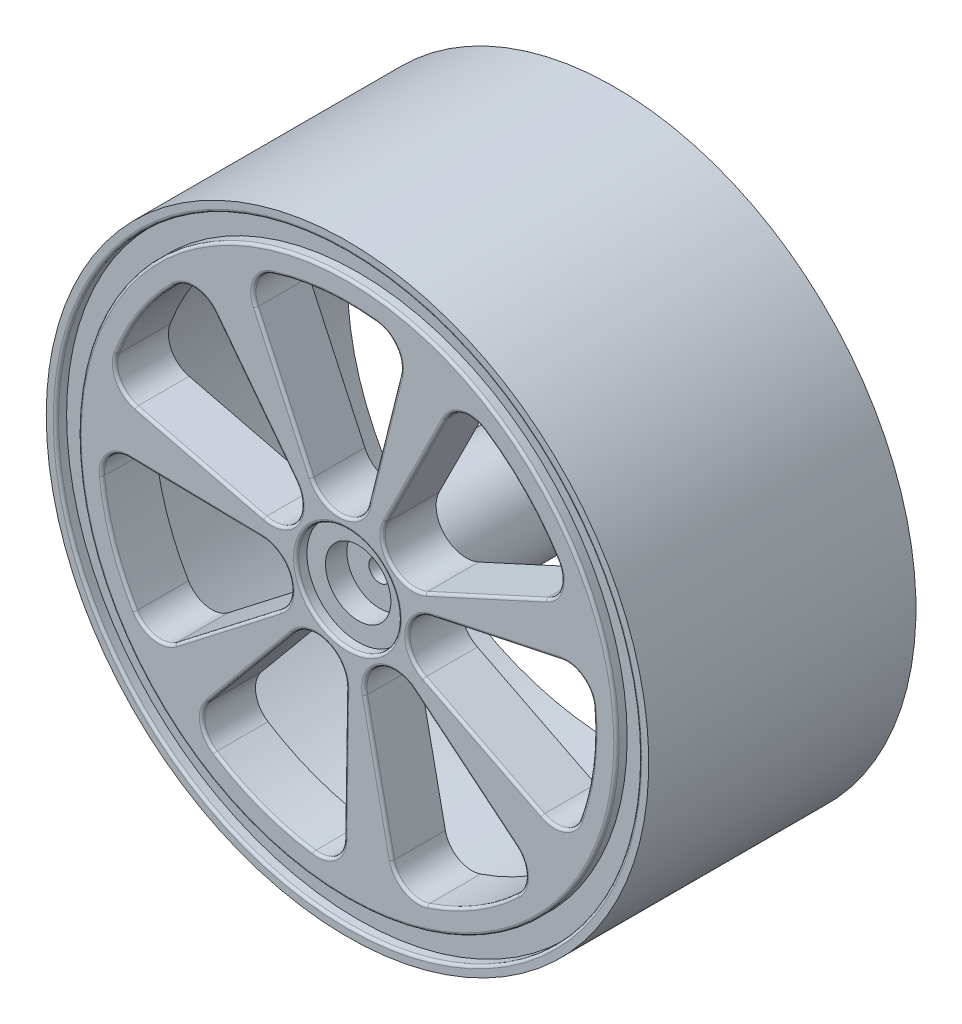
from build123d import *

# Parameters (mm, degrees)
MODEL_R             = 5
EXTRUDE_1_DEPTH     = 20
SKETCH_2_R          = 33
EXTRUDE_2_DEPTH     = 5
SKETCH_3_R          = 33
SKETCH_3_R_2        = 25
EXTRUDE_3_DEPTH     = 20
SKETCH_4_R          = 33
SKETCH_4_R_2        = 28.19022281
CUT_EXTRUDE_1_DEPTH = 25
SKETCH_5_R          = 3.061619724
CUT_EXTRUDE_3_DEPTH = 3
SKETCH_6_R          = 4.800333219
CUT_EXTRUDE_4_DEPTH = 1
SKETCH_7_R          = 1
CUT_EXTRUDE_5_DEPTH = 40
CUT_EXTRUDE_6_DEPTH = 40
FILLET_1_R          = 0.25
FILLET_3_R          = 0.25
FILLET_4_R          = 0.25
FILLET_5_R          = 0.25
FILLET_6_R          = 0.25
FILLET_7_R          = 0.25
FILLET_8_R          = 0.25
FILLET_9_R          = 0.25
SKETCH_9_R          = 27.284655203
SKETCH_9_R_2        = 25.169377032
CUT_EXTRUDE_7_DEPTH = 1
FILLET_10_R         = 0.25
FILLET_11_R         = 0.25


with BuildPart() as part:
    # Model → 凸台-拉伸1 (new body)
    with BuildSketch(Plane.XY):
        with Locations((797.832325437, 276.566635927)):
            Circle(MODEL_R)
        with BuildLine():
            Line((796.170809224, 277.679903133), (798.853062492, 278.286547512))
            ThreePointArc((798.853062492, 278.286547512), (798.273521349, 274.615906277), (796.170809224, 277.679903133))
        make_face(mode=Mode.SUBTRACT)
    extrude(amount=EXTRUDE_1_DEPTH)

    # 草图2 → 凸台-拉伸2 (add)
    with BuildSketch(Plane.XY.offset(20)):
        with Locations((797.832325437, 276.566635927)):
            Circle(SKETCH_2_R)
    extrude(amount=EXTRUDE_2_DEPTH)

    # 草图3 → 凸台-拉伸3 (add)
    with BuildSketch(Plane(origin=(0, 0, 20), x_dir=(-1, 0, 0), z_dir=(0, 0, -1))):
        with Locations((-797.832325437, 276.566635927)):
            Circle(SKETCH_3_R)
        with Locations((-797.832325437, 276.566635927)):
            Circle(SKETCH_3_R_2, mode=Mode.SUBTRACT)
    extrude(amount=EXTRUDE_3_DEPTH)

    # 草图4 → 切除-拉伸1 (cut)
    with BuildSketch(Plane(origin=(0, 0, 0), x_dir=(-1, 0, 0), z_dir=(0, 0, -1))):
        with Locations((-797.832325437, 276.566635927)):
            Circle(SKETCH_4_R)
        with Locations((-797.832325437, 276.566635927)):
            Circle(SKETCH_4_R_2, mode=Mode.SUBTRACT)
    extrude(amount=-CUT_EXTRUDE_1_DEPTH, mode=Mode.SUBTRACT)

    # 草图5 → 切除-拉伸3 (cut)
    with BuildSketch(Plane.XY.offset(25)):
        with Locations((797.832325437, 276.566635927)):
            Circle(SKETCH_5_R)
    extrude(amount=-CUT_EXTRUDE_3_DEPTH, mode=Mode.SUBTRACT)

    # 草图6 → 切除-拉伸4 (cut)
    with BuildSketch(Plane.XY.offset(25)):
        with Locations((797.832325437, 276.566635927)):
            Circle(SKETCH_6_R)
    extrude(amount=-CUT_EXTRUDE_4_DEPTH, mode=Mode.SUBTRACT)

    # 草图7 → 切除-拉伸5 (cut)
    with BuildSketch(Plane.XY.offset(22)):
        with Locations((797.832325437, 276.566635927)):
            Circle(SKETCH_7_R)
    extrude(amount=-CUT_EXTRUDE_5_DEPTH, mode=Mode.SUBTRACT)

    # 草图8 → 切除-拉伸6 (cut)
    with BuildSketch(Plane.XY.offset(25)):
        with BuildLine():
            Line((790.042110116, 278.468110041), (778.012217233, 281.404425532))
            ThreePointArc((778.012217233, 281.404425532), (776.366329321, 282.689917741), (776.240266413, 284.774514915))
            ThreePointArc((776.240266413, 284.774514915), (778.487037526, 289.189873469), (781.623633956, 293.024600895))
            ThreePointArc((781.623633956, 293.024600895), (783.582470105, 293.748754318), (785.421959492, 292.759959074))
            Line((785.421959492, 292.759959074), (792.954480073, 282.931357692))
            ThreePointArc((792.954480073, 282.931357692), (793.078123539, 279.668860104), (790.042110116, 278.468110041))
        make_face()
        with BuildLine():
            Line((799.76717845, 284.348628111), (802.755038675, 296.365822572))
            ThreePointArc((802.755038675, 296.365822572), (802.381207054, 298.420497037), (800.593726747, 299.500474532))
            ThreePointArc((800.593726747, 299.500474532), (795.639980232, 299.561850927), (790.787075032, 298.565516287))
            ThreePointArc((790.787075032, 298.565516287), (789.23587027, 297.167231257), (789.257026319, 295.078932988))
            Line((789.257026319, 295.078932988), (794.461837956, 283.842821238))
            ThreePointArc((794.461837956, 283.842821238), (797.293545565, 282.217825782), (799.76717845, 284.348628111))
        make_face()
        with BuildLine():
            Line((805.122893045, 279.905899692), (816.381214385, 285.062494696))
            ThreePointArc((816.381214385, 285.062494696), (817.754543364, 286.635836602), (817.484428028, 288.706699935))
            ThreePointArc((817.484428028, 288.706699935), (814.443803593, 292.617962472), (810.639100903, 295.790912052))
            ThreePointArc((810.639100903, 295.790912052), (808.578717295, 296.131876314), (806.959210545, 294.813303175))
            Line((806.959210545, 294.813303175), (801.419611614, 283.738416488))
            ThreePointArc((801.419611614, 283.738416488), (801.914679824, 280.511330235), (805.122893045, 279.905899692))
        make_face()
        with BuildLine():
            Line((804.98866153, 272.948637549), (816.039698389, 267.361611883))
            ThreePointArc((816.039698389, 267.361611883), (818.126043237, 267.268862684), (819.576695229, 268.771209527))
            ThreePointArc((819.576695229, 268.771209527), (820.738845089, 273.587097742), (820.847363637, 278.540035791))
            ThreePointArc((820.847363637, 278.540035791), (819.829312064, 280.363496301), (817.788664129, 280.80756076))
            Line((817.788664129, 280.80756076), (805.676085613, 278.233514698))
            ThreePointArc((805.676085613, 278.233514698), (803.461717964, 275.834399417), (804.98866153, 272.948637549))
        make_face()
        with BuildLine():
            Line((799.465562974, 268.715801978), (801.987659197, 256.592299923))
            ThreePointArc((801.987659197, 256.592299923), (803.215959689, 254.903301658), (805.295008471, 254.705834196))
            ThreePointArc((805.295008471, 254.705834196), (809.78481008, 256.799886036), (813.724833185, 259.803149181))
            ThreePointArc((813.724833185, 259.803149181), (814.515727246, 261.736002984), (813.590587643, 263.608315446))
            Line((813.590587643, 263.608315446), (804.026048216, 271.473419194))
            ThreePointArc((804.026048216, 271.473419194), (800.769708713, 271.708857625), (799.465562974, 268.715801978))
        make_face()
        with BuildLine():
            Line((792.712603241, 270.394804498), (784.80656893, 260.864070376))
            ThreePointArc((784.80656893, 260.864070376), (784.251889743, 258.850673187), (785.393769178, 257.102088447))
            ThreePointArc((785.393769178, 257.102088447), (789.830310348, 254.897440166), (794.634920251, 253.689510004))
            ThreePointArc((794.634920251, 253.689510004), (796.639200586, 254.276278763), (797.526218306, 256.166949755))
            Line((797.526218306, 256.166949755), (797.712011237, 268.548619773))
            ThreePointArc((797.712011237, 268.548619773), (795.865789943, 271.241321975), (792.712603241, 270.394804498))
        make_face()
        with BuildLine():
            Line((789.814898744, 276.721321967), (777.43413899, 276.960192962))
            ThreePointArc((777.43413899, 276.960192962), (775.514164865, 276.138525999), (774.859016448, 274.155543954))
            ThreePointArc((774.859016448, 274.155543954), (775.901491189, 269.312340675), (777.952718636, 264.802813255))
            ThreePointArc((777.952718636, 264.802813255), (779.661121274, 263.601648126), (781.692353881, 264.08696383))
            Line((781.692353881, 264.08696383), (791.488573304, 271.661550053))
            ThreePointArc((791.488573304, 271.661550053), (792.44271251, 274.783856347), (789.814898744, 276.721321967))
        make_face()
    extrude(amount=-CUT_EXTRUDE_6_DEPTH, mode=Mode.SUBTRACT)

    # 圆角1
    fillet_1_edges = [part.edges().sort_by_distance(p)[0] for p in [
        (793.031992218, 276.566635927, 25),
    ]]
    fillet(fillet_1_edges, radius=FILLET_1_R)

    # 圆角3
    fillet_3_edges = [part.edges().sort_by_distance(p)[0] for p in [
        (817.754543364, 286.635836602, 25),
        (814.443803593, 292.617962472, 25),
        (808.578717295, 296.131876314, 25),
        (804.18941108, 289.275859832, 25),
        (801.914679824, 280.511330235, 25),
        (810.752053715, 282.484197194, 25),
    ]]
    fillet(fillet_3_edges, radius=FILLET_3_R)

    # 圆角4
    fillet_4_edges = [part.edges().sort_by_distance(p)[0] for p in [
        (802.381207054, 298.420497037, 25),
        (795.639980232, 299.561850927, 25),
        (789.23587027, 297.167231257, 25),
        (791.859432138, 289.460877113, 25),
        (797.293545565, 282.217825782, 25),
        (801.261108563, 290.357225342, 25),
    ]]
    fillet(fillet_4_edges, radius=FILLET_4_R)

    # 圆角5
    fillet_5_edges = [part.edges().sort_by_distance(p)[0] for p in [
        (783.582470105, 293.748754318, 25),
        (778.487037526, 289.189873469, 25),
        (776.366329321, 282.689917741, 25),
        (784.027163675, 279.936267787, 25),
        (793.078123539, 279.668860104, 25),
        (789.188219782, 287.845658383, 25),
    ]]
    fillet(fillet_5_edges, radius=FILLET_5_R)

    # 圆角6
    fillet_6_edges = [part.edges().sort_by_distance(p)[0] for p in [
        (775.514164865, 276.138525999, 25),
        (775.901491189, 269.312340675, 25),
        (779.661121274, 263.601648126, 25),
        (786.590463593, 267.874256941, 25),
        (792.44271251, 274.783856347, 25),
        (783.624518867, 276.840757464, 25),
    ]]
    fillet(fillet_6_edges, radius=FILLET_6_R)

    # 圆角7
    fillet_7_edges = [part.edges().sort_by_distance(p)[0] for p in [
        (784.251889743, 258.850673187, 25),
        (789.830310348, 254.897440166, 25),
        (796.639200586, 254.276278763, 25),
        (797.619114771, 262.357784764, 25),
        (795.865789943, 271.241321975, 25),
        (788.759586085, 265.629437437, 25),
    ]]
    fillet(fillet_7_edges, radius=FILLET_7_R)

    # 圆角8
    fillet_8_edges = [part.edges().sort_by_distance(p)[0] for p in [
        (803.215959689, 254.903301658, 25),
        (809.78481008, 256.799886036, 25),
        (814.515727246, 261.736002984, 25),
        (808.80831793, 267.54086732, 25),
        (800.769708713, 271.708857625, 25),
        (800.726611085, 262.65405095, 25),
    ]]
    fillet(fillet_8_edges, radius=FILLET_8_R)

    # 圆角9
    fillet_9_edges = [part.edges().sort_by_distance(p)[0] for p in [
        (818.126043237, 267.268862684, 25),
        (820.738845089, 273.587097742, 25),
        (819.829312064, 280.363496301, 25),
        (811.732374871, 279.520537729, 25),
        (803.461717964, 275.834399417, 25),
        (810.514179959, 270.155124716, 25),
    ]]
    fillet(fillet_9_edges, radius=FILLET_9_R)

    # 草图9 → 切除-拉伸7 (cut)
    with BuildSketch(Plane.XY.offset(25)):
        with Locations((797.832325437, 276.566635927)):
            Circle(SKETCH_9_R)
        with Locations((797.832325437, 276.566635927)):
            Circle(SKETCH_9_R_2, mode=Mode.SUBTRACT)
    extrude(amount=-CUT_EXTRUDE_7_DEPTH, mode=Mode.SUBTRACT)

    # 圆角10
    fillet_10_edges = [part.edges().sort_by_distance(p)[0] for p in [
        (770.547670234, 276.566635927, 25),
    ]]
    fillet(fillet_10_edges, radius=FILLET_10_R)

    # 圆角11
    fillet_11_edges = [part.edges().sort_by_distance(p)[0] for p in [
        (772.662948405, 276.566635927, 25),
    ]]
    fillet(fillet_11_edges, radius=FILLET_11_R)


solid = part.part
